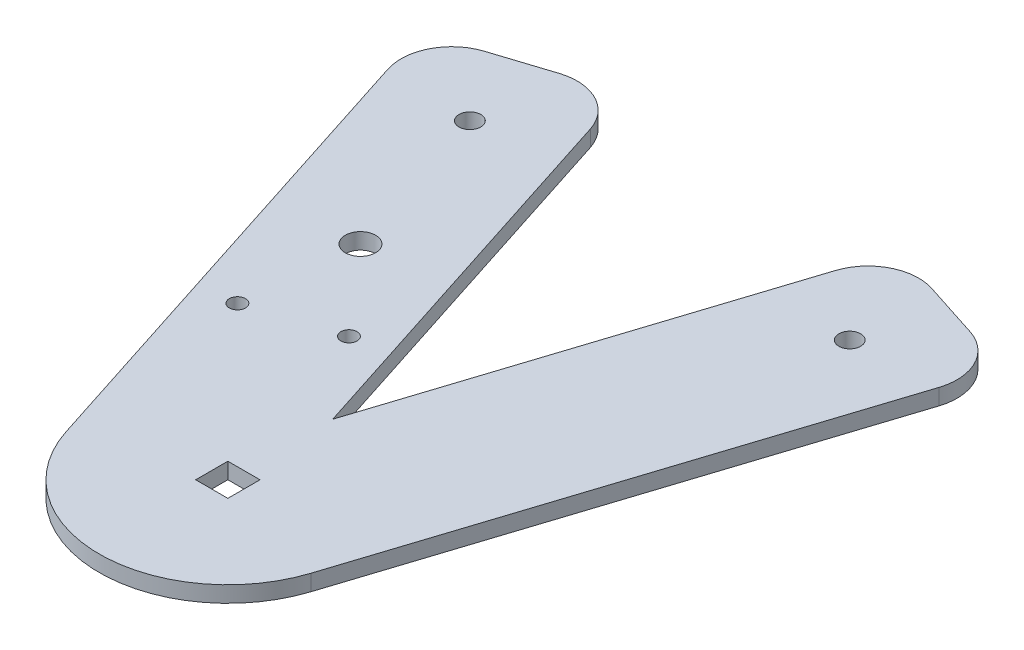
from build123d import *

# Parameters (mm, degrees)
SKETCH1_R           = 2.15
SKETCH1_R_2         = 3
SKETCH1_R_3         = 1.6
SKETCH1_W           = 6.35
SKETCH1_H           = 6.35
BOSS_EXTRUDE1_DEPTH = 3.175
FILLET1_R           = 10


with BuildPart() as part:
    # Sketch1 → Boss-Extrude1 (new body)
    with BuildSketch(Plane(origin=(0, 0, 0), x_dir=(1, 0, 0), z_dir=(0, 1, 0))):
        with BuildLine():
            Line((-57.479624947, 95.534974299), (-24.175240451, -7.792159464))
            ThreePointArc((-24.175240451, -7.792159464), (0, -25.4), (24.175240451, -7.792159464))
            Line((24.175240451, -7.792159464), (57.479624947, 95.534974299))
            Line((57.479624947, 95.534974299), (27.260574383, 105.27517363))
            Line((27.260574383, 105.27517363), (0, 20.69901171))
            Line((0, 20.69901171), (-27.260574383, 105.27517363))
            Line((-27.260574383, 105.27517363), (-57.479624947, 95.534974299))
        make_face()
        with Locations((37.5, 85.295548682)):
            Circle(SKETCH1_R, mode=Mode.SUBTRACT)
        with Locations((-37.5, 85.295548682)):
            Circle(SKETCH1_R, mode=Mode.SUBTRACT)
        with Locations((-27.222939289, 53.410881158)):
            Circle(SKETCH1_R_2, mode=Mode.SUBTRACT)
        with Locations((-29.231398698, 31.119883181)):
            Circle(SKETCH1_R_3, mode=Mode.SUBTRACT)
        with Locations((-12.575229096, 36.488496985)):
            Circle(SKETCH1_R_3, mode=Mode.SUBTRACT)
        Rectangle(SKETCH1_W, SKETCH1_H, mode=Mode.SUBTRACT)
    extrude(amount=BOSS_EXTRUDE1_DEPTH)

    # Fillet1
    fillet1_edges = [part.edges().sort_by_distance(p)[0] for p in [
        (-27.260574383, 1.5875, -105.27517363),
        (27.260574383, 1.5875, -105.27517363),
        (57.479624947, 1.5875, -95.534974299),
        (-57.479624947, 1.5875, -95.534974299),
    ]]
    fillet(fillet1_edges, radius=FILLET1_R)


solid = part.part
